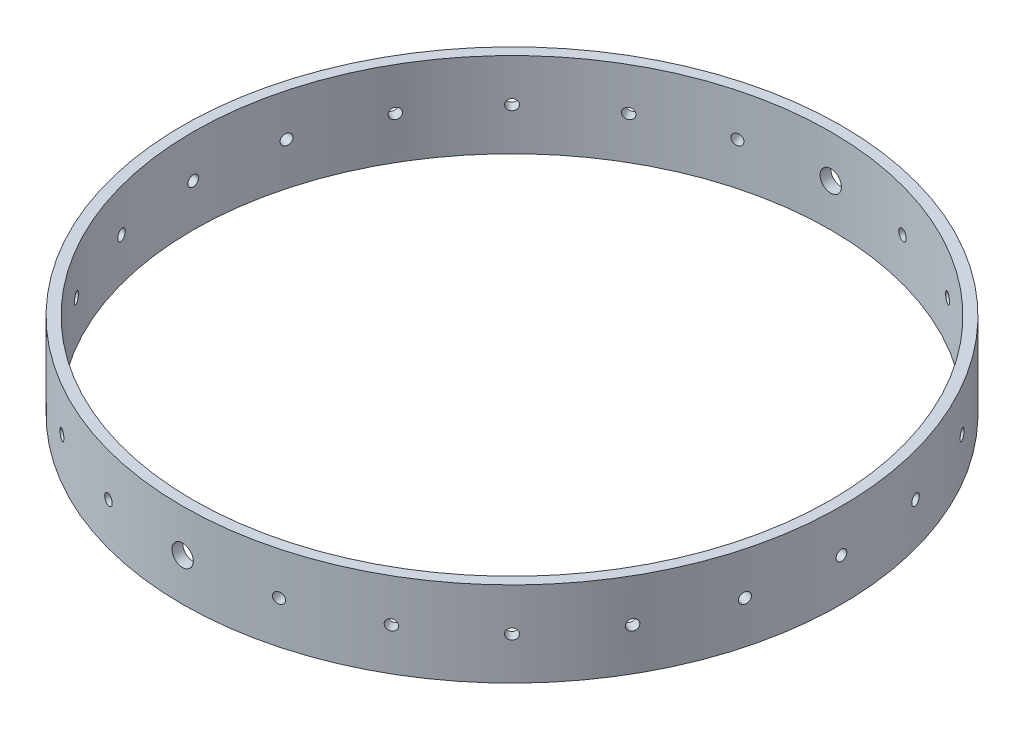
from build123d import *

# Parameters (mm, degrees)
SKETCH1_R               = 98.425
SKETCH1_R_2             = 95.25
BOSS_EXTRUDE1_DEPTH     = 25.4
SKETCH2_R               = 3.175
CUT_EXTRUDE1_DEPTH      = 99.425
CUT_EXTRUDE1_DEPTH_BACK = 99.425
SKETCH3_R               = 1.5875
CUT_EXTRUDE3_DEPTH      = 99.4250001
CIRPATTERN1_COUNT       = 24


with BuildPart() as part:
    # Sketch1 → Boss-Extrude1 (new body)
    with BuildSketch(Plane(origin=(0, 0, 0), x_dir=(1, 0, 0), z_dir=(0, 1, 0))):
        Circle(SKETCH1_R)
        Circle(SKETCH1_R_2, mode=Mode.SUBTRACT)
    extrude(amount=BOSS_EXTRUDE1_DEPTH)

    # Sketch2 → Cut-Extrude1 (cut, two sides)
    with BuildSketch(Plane.XY) as cut_extrude1_sk:
        with Locations((0, 12.7)):
            Circle(SKETCH2_R)
    extrude(amount=CUT_EXTRUDE1_DEPTH, mode=Mode.SUBTRACT)
    extrude(cut_extrude1_sk.sketch, amount=-CUT_EXTRUDE1_DEPTH_BACK, mode=Mode.SUBTRACT)

    # Sketch3 → Cut-Extrude3 (cut, through all)
    with BuildSketch(Plane(origin=(0, 0, 0), x_dir=(0, 0, -1), z_dir=(1, 0, 0))):
        with Locations((0, 12.7)):
            Circle(SKETCH3_R)
    cut_extrude3 = extrude(amount=-CUT_EXTRUDE3_DEPTH, mode=Mode.SUBTRACT)

    # CirPattern1: Cut-Extrude3 ×24 about axis
    cirpattern1_axis = Axis((0, 0, 0), (0, 1, 0))
    for i in range(1, CIRPATTERN1_COUNT):
        add(cut_extrude3.rotate(cirpattern1_axis, i * 360 / CIRPATTERN1_COUNT), mode=Mode.SUBTRACT)


solid = part.part
